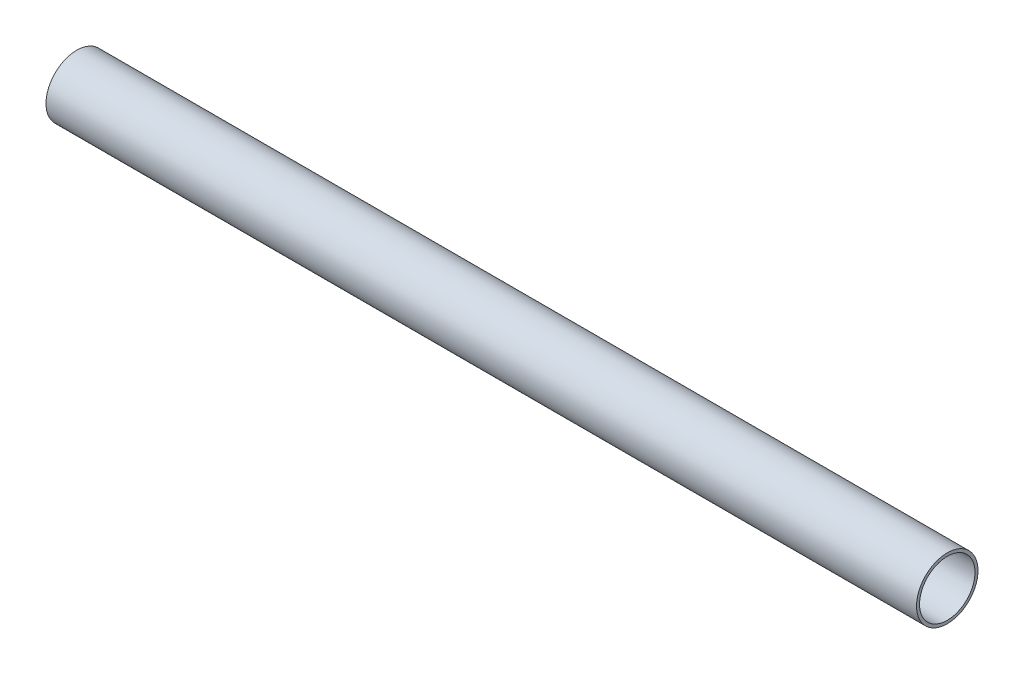
from build123d import *

# Parameters (mm, degrees)
SKETCH1_W = 188.3
SKETCH1_H = 0.65


with BuildPart() as part:
    # Sketch1 → Revolve1 (revolve)
    with BuildSketch(Plane.XY):
        with Locations((-676.748230203, -6.325440289)):
            Rectangle(SKETCH1_W, SKETCH1_H)
    revolve(axis=Axis((-766.248230203, -0.000440289, 0), (1, 0, 0)))


solid = part.part
